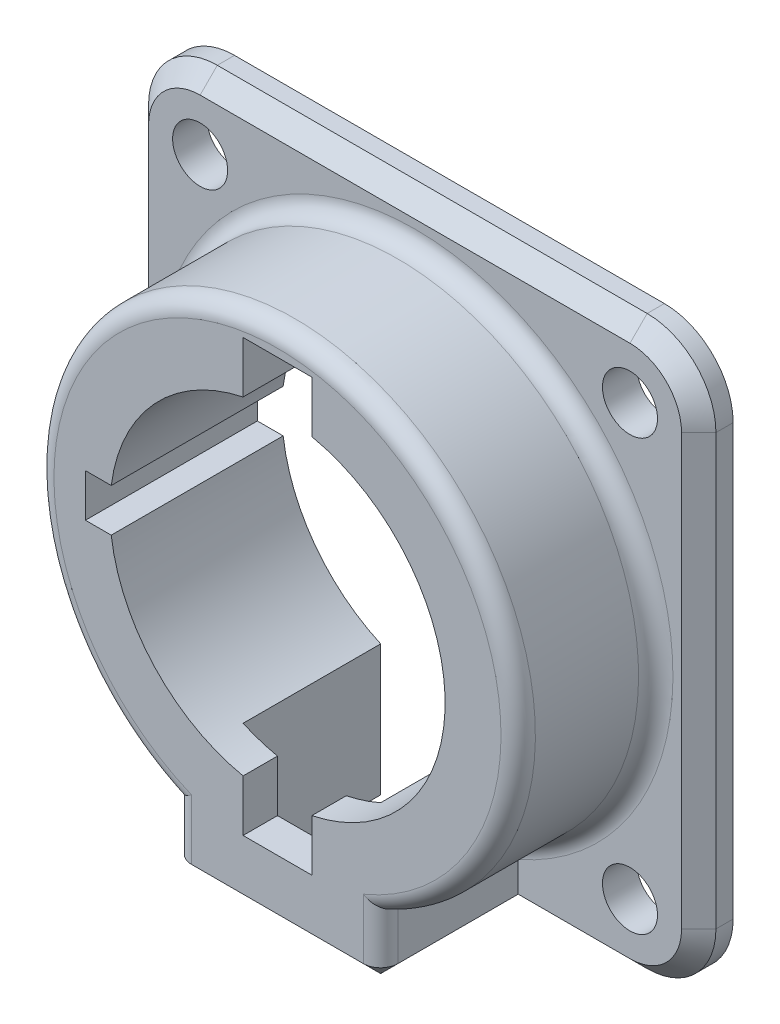
from build123d import *

# Parameters (mm, degrees)
SKETCH1_R           = 1.6
BOSS_EXTRUDE1_DEPTH = 2
BOSS_EXTRUDE3_DEPTH = 10
CUT_EXTRUDE2_DEPTH  = 26.38700455
CUT_EXTRUDE3_DEPTH  = 8
CHAMFER1_SIZE       = 1
FILLET4_R           = 1
CHAMFER2_SIZE       = 1


with BuildPart() as part:
    # Sketch1 → Boss-Extrude1 (new body)
    with BuildSketch(Plane.XY):
        with BuildLine():
            Line((-12.5, -16.5), (12.5, -16.5))
            ThreePointArc((12.5, -16.5), (15.328427125, -15.328427125), (16.5, -12.5))
            Line((16.5, -12.5), (16.5, 12.5))
            ThreePointArc((16.5, 12.5), (15.328427125, 15.328427125), (12.5, 16.5))
            Line((12.5, 16.5), (-12.5, 16.5))
            ThreePointArc((-12.5, 16.5), (-15.328427125, 15.328427125), (-16.5, 12.5))
            Line((-16.5, 12.5), (-16.5, -12.5))
            ThreePointArc((-16.5, -12.5), (-15.328427125, -15.328427125), (-12.5, -16.5))
        make_face()
        with Locations((-12.5, -12.5)):
            Circle(SKETCH1_R, mode=Mode.SUBTRACT)
        with Locations((12.5, -12.5)):
            Circle(SKETCH1_R, mode=Mode.SUBTRACT)
        with Locations((12.5, 12.5)):
            Circle(SKETCH1_R, mode=Mode.SUBTRACT)
        with Locations((-12.5, 12.5)):
            Circle(SKETCH1_R, mode=Mode.SUBTRACT)
    extrude(amount=BOSS_EXTRUDE1_DEPTH)

    # Sketch3 → Boss-Extrude3 (add)
    with BuildSketch(Plane.XY):
        with BuildLine():
            ThreePointArc((6, -12.649110641), (0, 14), (-6, -12.649110641))
            Line((-6, -12.649110641), (-6, -16.5))
            Line((-6, -16.5), (6, -16.5))
            Line((6, -16.5), (6, -12.649110641))
        make_face()
    extrude(amount=BOSS_EXTRUDE3_DEPTH)

    # Sketch3_3 → Cut-Extrude2 (cut, through all)
    with BuildSketch(Plane.XY):
        with BuildLine():
            Line((-11.169539803, -1.25), (-9.669539803, -1.25))
            ThreePointArc((-9.669539803, -1.25), (-7.15797616, -6.620111577), (-2, -9.542667342))
            Line((-2, -9.542667342), (-2, -12.542667342))
            Line((-2, -12.542667342), (2, -12.542667342))
            Line((2, -12.542667342), (2, -9.542667342))
            ThreePointArc((2, -9.542667342), (9.75, 0), (2, 9.542667342))
            Line((2, 9.542667342), (2, 12.542667342))
            Line((2, 12.542667342), (-2, 12.542667342))
            Line((-2, 12.542667342), (-2, 9.542667342))
            ThreePointArc((-2, 9.542667342), (-7.15797616, 6.620111577), (-9.669539803, 1.25))
            Line((-9.669539803, 1.25), (-11.169539803, 1.25))
            Line((-11.169539803, 1.25), (-11.169539803, -1.25))
        make_face()
    extrude(amount=CUT_EXTRUDE2_DEPTH, mode=Mode.SUBTRACT)

    # Sketch3_4 → Cut-Extrude3 (cut)
    with BuildSketch(Plane.XY):
        with BuildLine():
            ThreePointArc((-2, -9.542667342), (-3.017604429, -9.271276261), (-4, -8.891709622))
            Line((-4, -8.891709622), (-4, -16.5))
            Line((-4, -16.5), (4, -16.5))
            Line((4, -16.5), (4, -8.891709622))
            ThreePointArc((4, -8.891709622), (3.017604429, -9.271276261), (2, -9.542667342))
            Line((2, -9.542667342), (2, -12.542667342))
            Line((2, -12.542667342), (-2, -12.542667342))
            Line((-2, -12.542667342), (-2, -9.542667342))
        make_face()
    extrude(amount=CUT_EXTRUDE3_DEPTH, mode=Mode.SUBTRACT)

    # Chamfer1
    chamfer1_edges = [part.edges().sort_by_distance(p)[0] for p in [
        (-15.328427125, -15.328427125, 2),
        (-9.25, -16.5, 2),
        (15.328427125, -15.328427125, 2),
        (16.5, 0, 2),
        (15.328427125, 15.328427125, 2),
        (0, 16.5, 2),
        (9.25, -16.5, 2),
        (-15.328427125, 15.328427125, 2),
        (-16.5, 0, 2),
    ]]
    chamfer(chamfer1_edges, length=CHAMFER1_SIZE)

    # Fillet4
    fillet4_edges = [part.edges().sort_by_distance(p)[0] for p in [
        (0, 14, 2),
        (6, -14.57455532, 10),
        (0, 14, 10),
        (-6, -14.57455532, 10),
    ]]
    fillet(fillet4_edges, radius=FILLET4_R)

    # Chamfer2
    chamfer2_edges = [part.edges().sort_by_distance(p)[0] for p in [
        (-6, -16.5, 5),
        (6, -16.5, 5),
        (-5.707106781, -16.5, 9.707106781),
        (5.707106781, -16.5, 9.707106781),
        (0, -16.5, 10),
    ]]
    chamfer(chamfer2_edges, length=CHAMFER2_SIZE)


solid = part.part
